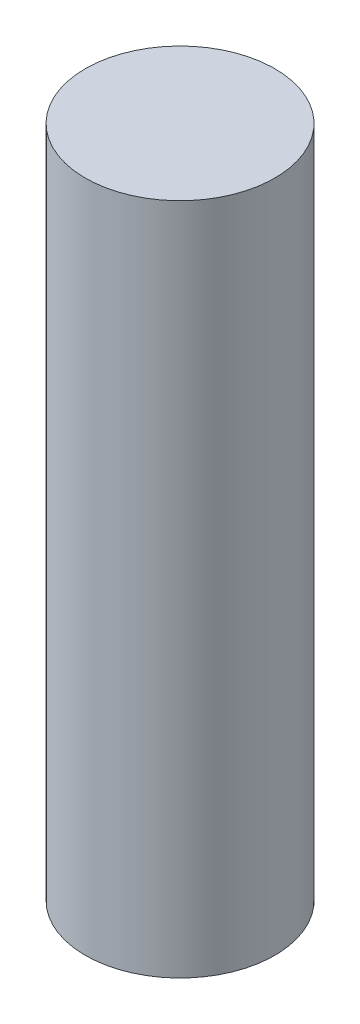
from build123d import *

# Parameters (mm, degrees)
SKETCH1_W = 9.15
SKETCH1_H = 65


with BuildPart() as part:
    # Sketch1 → Revolve1 (revolve)
    with BuildSketch(Plane.XY):
        with Locations((-4.575, 0)):
            Rectangle(SKETCH1_W, SKETCH1_H)
    revolve(axis=Axis((0, 32.5, 0), (0, -1, 0)))


solid = part.part
